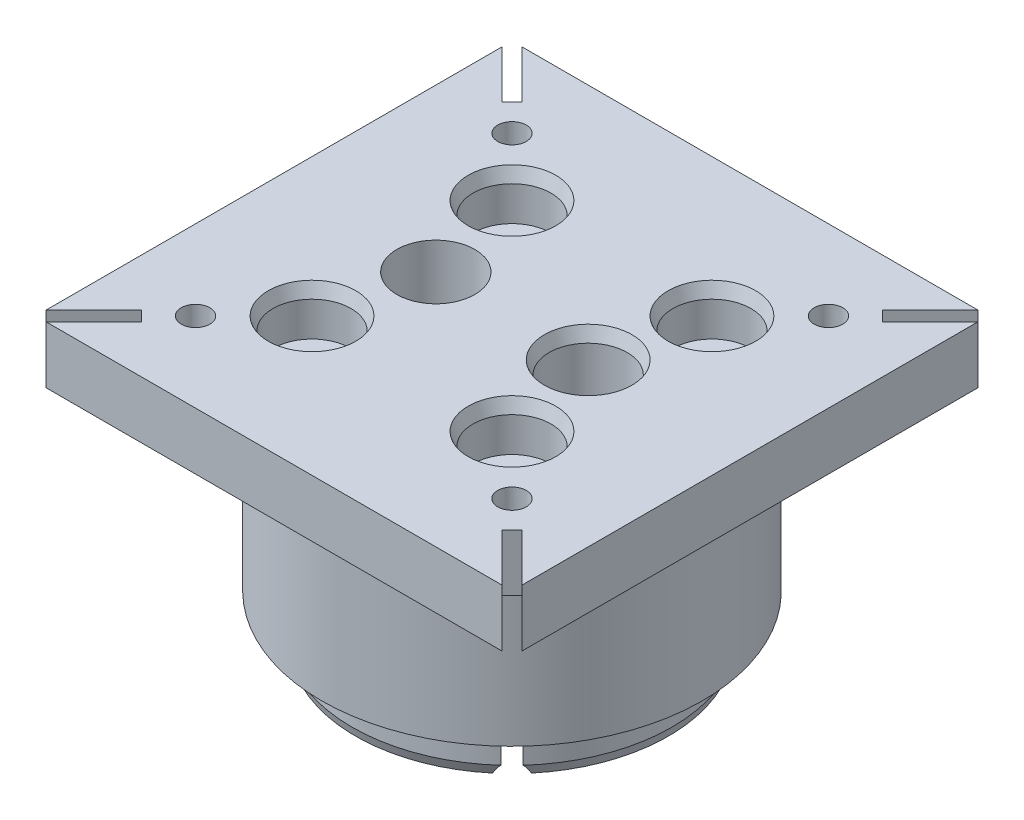
from build123d import *

# Parameters (mm, degrees)
SKETCH1_R             = 20
BOSS_EXTRUDE1_DEPTH   = 25
SKETCH3_R             = 16.8
BOSS_EXTRUDE2_DEPTH   = 5
SKETCH4_R             = 4.1
CUT_EXTRUDE1_DEPTH    = 31
SKETCH6_R             = 2.1
CUT_EXTRUDE2_DEPTH    = 31
CHAMFER1_SIZE         = 1
CHAMFER1_SIZE2        = 0.363970234
CHAMFER1_PART_2_SIZE  = 1
CHAMFER1_PART_2_SIZE2 = 0.363970234
CHAMFER1_PART_3_SIZE  = 1
CHAMFER1_PART_3_SIZE2 = 0.363970234
CHAMFER1_PART_4_SIZE  = 1
CHAMFER1_PART_4_SIZE2 = 0.363970234
SKETCH7_R             = 4.1
CUT_EXTRUDE3_DEPTH    = 5
CHAMFER2_SIZE         = 0.5
CHAMFER2_SIZE2        = 1.37373871
SKETCH8_W             = 50
SKETCH8_H             = 50
SKETCH8_R             = 20
SKETCH8_R_2           = 1.5
BOSS_EXTRUDE3_DEPTH   = 6
CUT_EXTRUDE4_DEPTH    = 31.0000001
CHAMFER3_SIZE         = 0.5
CHAMFER3_SIZE2        = 1.37373871
CUT_EXTRUDE5_DEPTH    = 6.5
CHAMFER4_SIZE         = 1


with BuildPart() as part:
    # Sketch1 → Boss-Extrude1 (new body)
    with BuildSketch(Plane(origin=(0, 0, 0), x_dir=(1, 0, 0), z_dir=(0, 1, 0))):
        Circle(SKETCH1_R)
    extrude(amount=BOSS_EXTRUDE1_DEPTH)

    # Sketch3 → Boss-Extrude2 (add)
    with BuildSketch(Plane.XZ):
        Circle(SKETCH3_R)
    extrude(amount=BOSS_EXTRUDE2_DEPTH)

    # Sketch4 → Cut-Extrude1 (cut, through all)
    with BuildSketch(Plane(origin=(0, 25, 0), x_dir=(1, 0, 0), z_dir=(0, 1, 0))):
        with Locations((8, 0)):
            Circle(SKETCH4_R)
        with Locations((-8, 0)):
            Circle(SKETCH4_R)
    extrude(amount=-CUT_EXTRUDE1_DEPTH, mode=Mode.SUBTRACT)

    # Sketch6 → Cut-Extrude2 (cut, through all)
    with BuildSketch(Plane(origin=(0, 25, 0), x_dir=(1, 0, 0), z_dir=(0, 1, 0))):
        with Locations((10.5, -10.5)):
            Circle(SKETCH6_R)
        with Locations((-10.5, -10.5)):
            Circle(SKETCH6_R)
        with Locations((-10.5, 10.5)):
            Circle(SKETCH6_R)
        with Locations((10.5, 10.5)):
            Circle(SKETCH6_R)
    extrude(amount=-CUT_EXTRUDE2_DEPTH, mode=Mode.SUBTRACT)

    # Chamfer1
    chamfer1_edges = [part.edges().sort_by_distance(p)[0] for p in [
        (0, -5, 16.8),
    ]]
    chamfer1_side = [part.faces().sort_by_distance(p)[0] for p in [
        (0, -2.5, 16.8),
    ]]
    chamfer(chamfer1_edges, length=CHAMFER1_SIZE, length2=CHAMFER1_SIZE2, reference=chamfer1_side[0])

    # Chamfer1 part 2
    chamfer1_part_2_edges = [part.edges().sort_by_distance(p)[0] for p in [
        (-16.8, -5, 0),
    ]]
    chamfer1_part_2_side = [part.faces().sort_by_distance(p)[0] for p in [
        (-16.8, -2.5, 0),
    ]]
    chamfer(chamfer1_part_2_edges, length=CHAMFER1_PART_2_SIZE, length2=CHAMFER1_PART_2_SIZE2, reference=chamfer1_part_2_side[0])

    # Chamfer1 part 3
    chamfer1_part_3_edges = [part.edges().sort_by_distance(p)[0] for p in [
        (0, -5, -16.8),
    ]]
    chamfer1_part_3_side = [part.faces().sort_by_distance(p)[0] for p in [
        (0, -2.5, -16.8),
    ]]
    chamfer(chamfer1_part_3_edges, length=CHAMFER1_PART_3_SIZE, length2=CHAMFER1_PART_3_SIZE2, reference=chamfer1_part_3_side[0])

    # Chamfer1 part 4
    chamfer1_part_4_edges = [part.edges().sort_by_distance(p)[0] for p in [
        (16.8, -5, 0),
    ]]
    chamfer1_part_4_side = [part.faces().sort_by_distance(p)[0] for p in [
        (16.8, -2.5, 0),
    ]]
    chamfer(chamfer1_part_4_edges, length=CHAMFER1_PART_4_SIZE, length2=CHAMFER1_PART_4_SIZE2, reference=chamfer1_part_4_side[0])

    # Sketch7 → Cut-Extrude3 (cut)
    with BuildSketch(Plane(origin=(0, 25, 0), x_dir=(1, 0, 0), z_dir=(0, 1, 0))):
        with Locations((10.5, 10.5)):
            Circle(SKETCH7_R)
        with Locations((-10.5, 10.5)):
            Circle(SKETCH7_R)
        with Locations((-10.5, -10.5)):
            Circle(SKETCH7_R)
        with Locations((10.5, -10.5)):
            Circle(SKETCH7_R)
    extrude(amount=-CUT_EXTRUDE3_DEPTH, mode=Mode.SUBTRACT)

    # Chamfer2
    chamfer2_edges = [part.edges().sort_by_distance(p)[0] for p in [
        (3.9, 25, 0),
    ]]
    chamfer2_side = [part.faces().sort_by_distance(p)[0] for p in [
        (0, 25, 0),
    ]]
    chamfer(chamfer2_edges, length=CHAMFER2_SIZE, length2=CHAMFER2_SIZE2, reference=chamfer2_side[0])

    # Sketch8 → Boss-Extrude3 (add)
    with BuildSketch(Plane(origin=(0, 25, 0), x_dir=(1, 0, 0), z_dir=(0, 1, 0))):
        Rectangle(SKETCH8_W, SKETCH8_H)
        Circle(SKETCH8_R, mode=Mode.SUBTRACT)
        with Locations((-16.617009358, -16.617009358)):
            Circle(SKETCH8_R_2, mode=Mode.SUBTRACT)
        with Locations((-16.617009358, 16.617009358)):
            Circle(SKETCH8_R_2, mode=Mode.SUBTRACT)
        with Locations((16.617009358, 16.617009358)):
            Circle(SKETCH8_R_2, mode=Mode.SUBTRACT)
        with Locations((16.617009358, -16.617009358)):
            Circle(SKETCH8_R_2, mode=Mode.SUBTRACT)
    extrude(amount=-BOSS_EXTRUDE3_DEPTH)

    # Sketch10 → Cut-Extrude4 (cut, through all)
    with BuildSketch(Plane(origin=(0, 25, 0), x_dir=(1, 0, 0), z_dir=(0, 1, 0))):
        Polygon((-19.975766569, -18.915106397), (-18.915106397, -19.975766569), (-23.939339828, -25), (-25, -25), (-25, -23.939339828), align=None)
        Polygon((-25, 23.939339828), (-19.975766569, 18.915106397), (-18.915106397, 19.975766569), (-23.939339828, 25), (-25, 25), align=None)
        Polygon((23.939339828, 25), (18.915106397, 19.975766569), (19.975766569, 18.915106397), (25, 23.939339828), (25, 25), align=None)
        Polygon((18.915106397, -19.975766569), (19.975766569, -18.915106397), (25, -23.939339828), (25, -25), (23.939339828, -25), align=None)
    extrude(amount=-CUT_EXTRUDE4_DEPTH, mode=Mode.SUBTRACT)

    # Chamfer3
    chamfer3_edges = [part.edges().sort_by_distance(p)[0] for p in [
        (6.4, 25, -10.5),
        (-14.6, 25, -10.5),
        (-14.6, 25, 10.5),
        (6.4, 25, 10.5),
    ]]
    chamfer3_side = [part.faces().sort_by_distance(p)[0] for p in [
        (-0.052152151, 25, 0),
    ]]
    chamfer(chamfer3_edges, length=CHAMFER3_SIZE, length2=CHAMFER3_SIZE2, reference=chamfer3_side[0])

    # Sketch11 → Cut-Extrude5 (cut)
    with BuildSketch(Plane.XZ.offset(5)):
        Polygon((-8, 7.5), (-14.495190528, 3.75), (-14.495190528, -3.75), (-8, -7.5), (-1.504809472, -3.75), (-1.504809472, 3.75), align=None)
        Polygon((8, 7.5), (1.504809472, 3.75), (1.504809472, -3.75), (8, -7.5), (14.495190528, -3.75), (14.495190528, 3.75), align=None)
    extrude(amount=-CUT_EXTRUDE5_DEPTH, mode=Mode.SUBTRACT)

    # Chamfer4
    chamfer4_edges = [part.edges().sort_by_distance(p)[0] for p in [
        (-20, 19, 0),
        (-4.752404736, -5, 5.625),
        (-11.247595264, -5, 5.625),
        (-14.495190528, -5, 0),
        (-11.247595264, -5, -5.625),
        (-4.752404736, -5, -5.625),
        (-1.504809472, -5, 0),
        (11.247595264, -5, 5.625),
        (4.752404736, -5, 5.625),
        (1.504809472, -5, 0),
        (4.752404736, -5, -5.625),
        (11.247595264, -5, -5.625),
        (14.495190528, -5, 0),
    ]]
    chamfer(chamfer4_edges, length=CHAMFER4_SIZE)


solid = part.part
